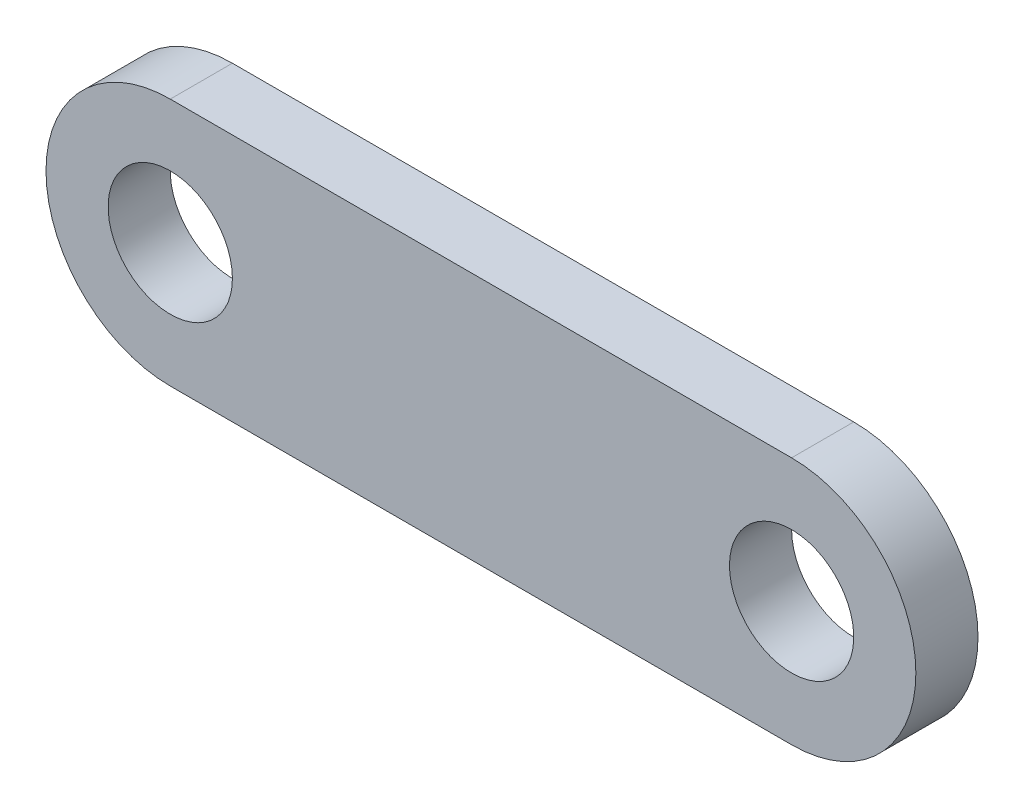
from build123d import *

# Parameters (mm, degrees)
SKETCH1_R           = 2
BOSS_EXTRUDE1_DEPTH = 2


with BuildPart() as part:
    # Sketch1 → Boss-Extrude1 (new body)
    with BuildSketch(Plane.XY):
        with BuildLine():
            Line((0, 4), (20, 4))
            ThreePointArc((20, 4), (24, 0), (20, -4))
            Line((20, -4), (0, -4))
            ThreePointArc((0, -4), (-4, 0), (0, 4))
        make_face()
        Circle(SKETCH1_R, mode=Mode.SUBTRACT)
        with Locations((20, 0)):
            Circle(SKETCH1_R, mode=Mode.SUBTRACT)
    extrude(amount=BOSS_EXTRUDE1_DEPTH)


solid = part.part
